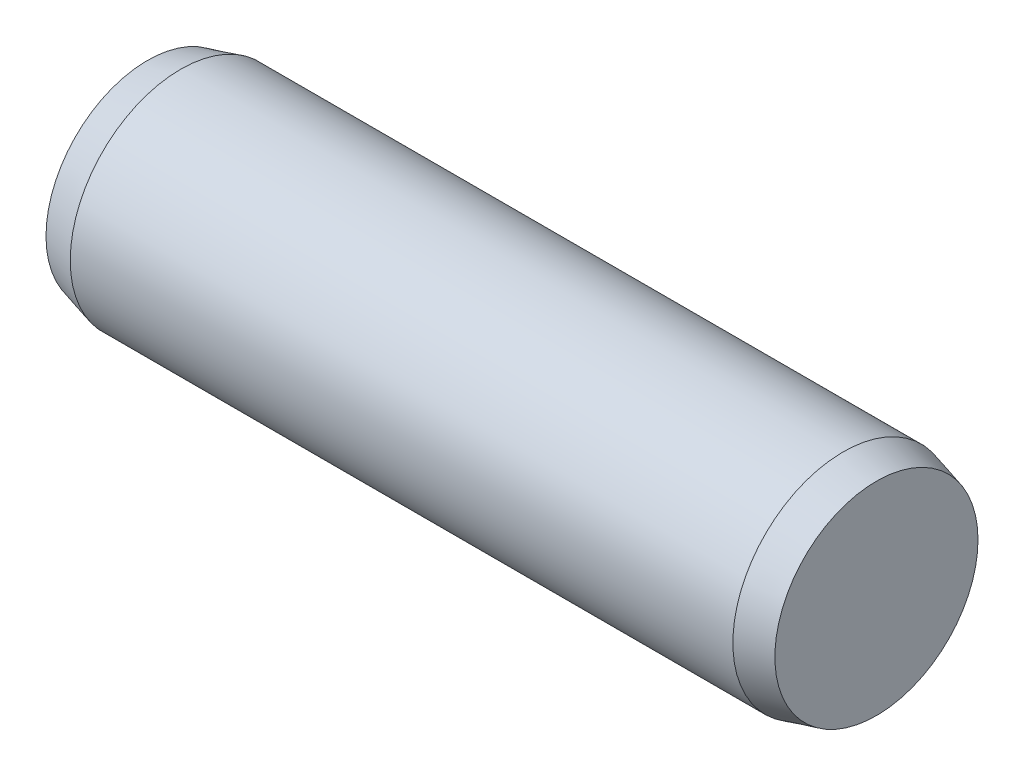
from build123d import *

# Parameters (mm, degrees)
SKETCH2_R           = 1
EXTRUDE1_DEPTH      = 3
EXTRUDE1_DEPTH_BACK = 3
SKETCH3_R           = 1
EXTRUDE2_DEPTH      = 0.3
EXTRUDE2_TAPER      = 15
SKETCH4_R           = 1
EXTRUDE3_DEPTH      = 0.3
EXTRUDE3_TAPER      = 15


with BuildPart() as part:
    # Sketch2 → Extrude1 (new body, two sides)
    with BuildSketch(Plane(origin=(0, 0, 0), x_dir=(0, 0, -1), z_dir=(1, 0, 0))) as extrude1_sk:
        Circle(SKETCH2_R)
    extrude(amount=EXTRUDE1_DEPTH)
    extrude(extrude1_sk.sketch, amount=-EXTRUDE1_DEPTH_BACK)

    # Sketch3 → Extrude2 (add)
    with BuildSketch(Plane(origin=(3, 0, 0), x_dir=(0, 0, -1), z_dir=(1, 0, 0))):
        Circle(SKETCH3_R)
    extrude(amount=EXTRUDE2_DEPTH, taper=EXTRUDE2_TAPER)

    # Sketch4 → Extrude3 (add)
    with BuildSketch(Plane.ZY.offset(3)):
        Circle(SKETCH4_R)
    extrude(amount=EXTRUDE3_DEPTH, taper=EXTRUDE3_TAPER)


solid = part.part
